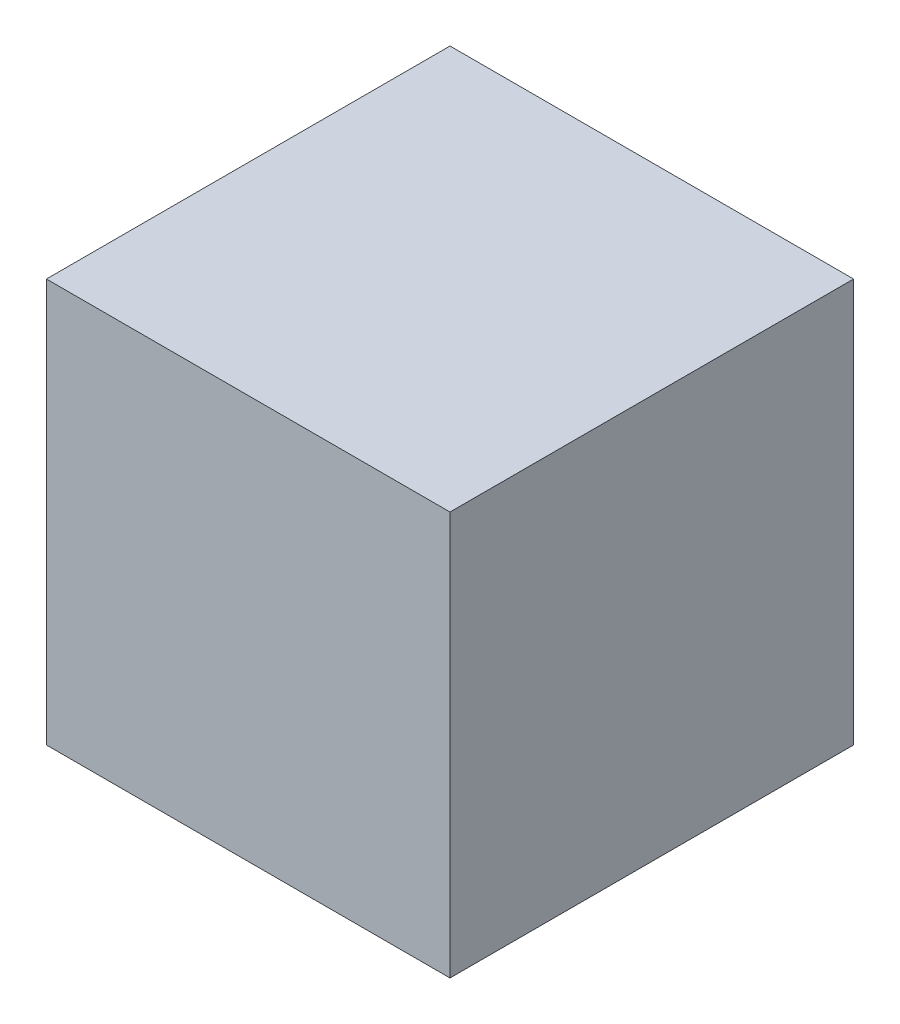
from build123d import *

# Parameters (mm, degrees)
CROQUIS3_W              = 500
CROQUIS3_H              = 500
SALIENTE_EXTRUIR1_DEPTH = 500


with BuildPart() as part:
    # Croquis3 → Saliente-Extruir1 (new body)
    with BuildSketch(Plane.XY):
        Rectangle(CROQUIS3_W, CROQUIS3_H)
    extrude(amount=SALIENTE_EXTRUIR1_DEPTH)


solid = part.part
